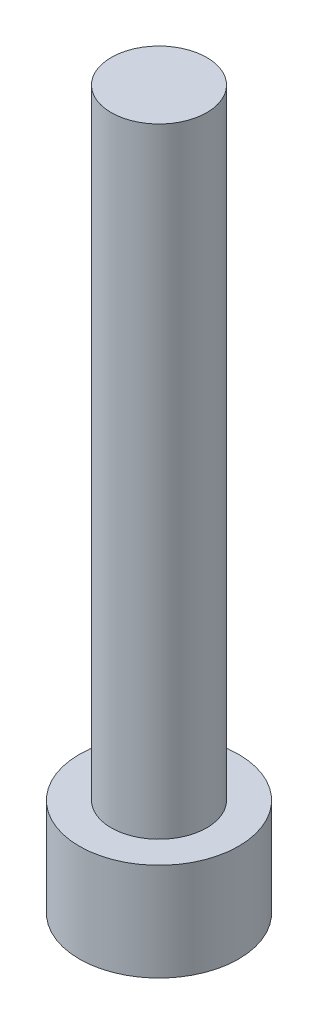
from build123d import *

# Parameters (mm, degrees)
SKETCH1_R           = 2.8575
BOSS_EXTRUDE1_DEPTH = 3.5052
CUT_EXTRUDE1_DEPTH  = 1.9558
SKETCH3_R           = 1.7145
BOSS_EXTRUDE2_DEPTH = 22.225


with BuildPart() as part:
    # Sketch1 → Boss-Extrude1 (new body)
    with BuildSketch(Plane(origin=(0, 0, 0), x_dir=(1, 0, 0), z_dir=(0, 1, 0))):
        Circle(SKETCH1_R)
    extrude(amount=BOSS_EXTRUDE1_DEPTH)

    # Sketch2 → Cut-Extrude1 (cut)
    with BuildSketch(Plane.XZ):
        Polygon((1.603951217, 0), (0.801975608, 1.3890625), (-0.801975608, 1.3890625), (-1.603951217, 0), (-0.801975608, -1.3890625), (0.801975608, -1.3890625), align=None)
    extrude(amount=-CUT_EXTRUDE1_DEPTH, mode=Mode.SUBTRACT)

    # Sketch3 → Boss-Extrude2 (add)
    with BuildSketch(Plane(origin=(0, 3.5052, 0), x_dir=(1, 0, 0), z_dir=(0, 1, 0))):
        Circle(SKETCH3_R)
    extrude(amount=BOSS_EXTRUDE2_DEPTH)


solid = part.part
